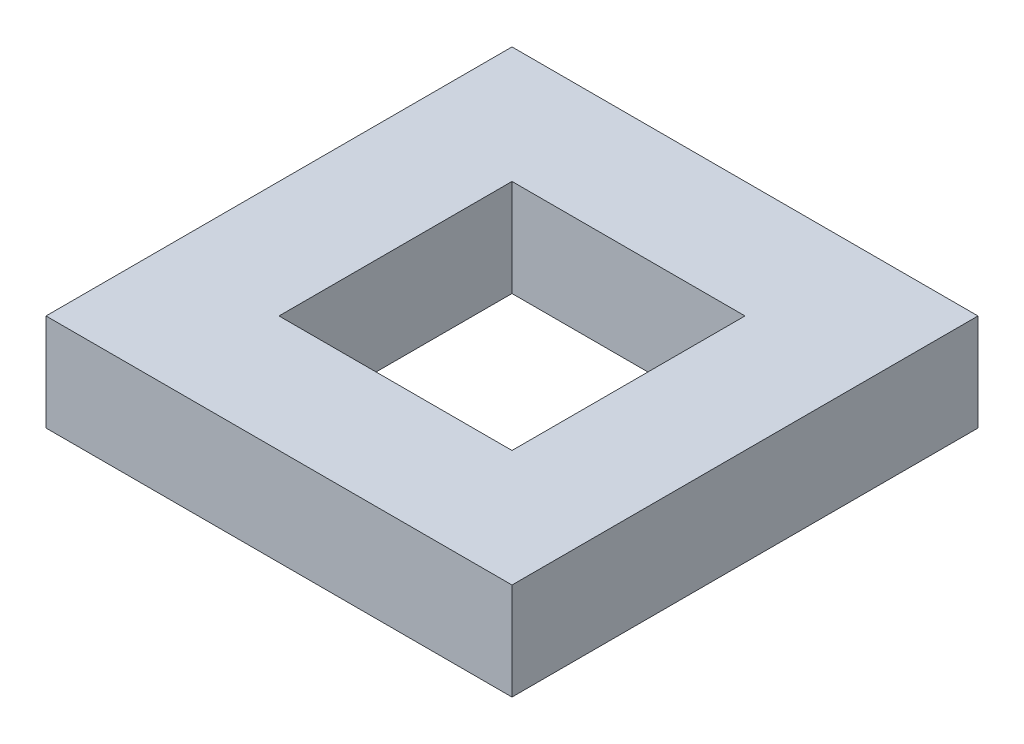
from build123d import *

# Parameters (mm, degrees)
SKETCH1_W           = 15.24
SKETCH1_H           = 15.24
SKETCH1_W_2         = 7.62
SKETCH1_H_2         = 7.62
BOSS_EXTRUDE1_DEPTH = 3.175


with BuildPart() as part:
    # Sketch1 → Boss-Extrude1 (new body)
    with BuildSketch(Plane(origin=(0, 0, 0), x_dir=(1, 0, 0), z_dir=(0, 1, 0))):
        with Locations((7.62, 7.62)):
            Rectangle(SKETCH1_W, SKETCH1_H)
        with Locations((7.62, 7.62)):
            Rectangle(SKETCH1_W_2, SKETCH1_H_2, mode=Mode.SUBTRACT)
    extrude(amount=BOSS_EXTRUDE1_DEPTH)


solid = part.part
